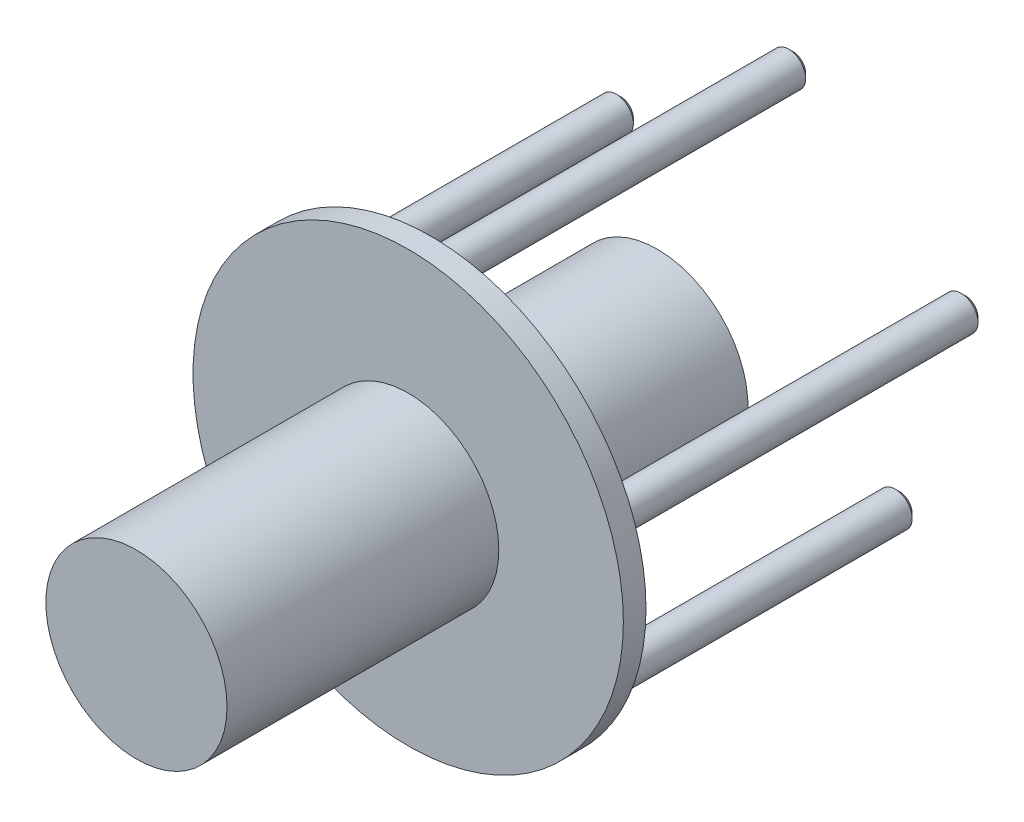
from build123d import *

# Parameters (mm, degrees)
SKETCH2_R             = 25.4
BOSS_EXTRUDE1_DEPTH   = 57.15
SKETCH2_R_2           = 4.7625
BOSS_EXTRUDE1_2_DEPTH = 57.15
BOSS_EXTRUDE1_3_DEPTH = 57.15
BOSS_EXTRUDE1_4_DEPTH = 57.15
BOSS_EXTRUDE1_5_DEPTH = 57.15
BOSS_EXTRUDE1_6_DEPTH = 57.15
SKETCH3_R             = 60.325
BOSS_EXTRUDE2_DEPTH   = 6.35
SKETCH4_R             = 25.4
BOSS_EXTRUDE3_DEPTH   = 6.35
SKETCH5_R             = 4.7625
BOSS_EXTRUDE4_DEPTH   = 44.45
CHAMFER1_SIZE         = 1.27
SKETCH7_R             = 25.4
BOSS_EXTRUDE5_DEPTH   = 76.2


with BuildPart() as part:
    # Sketch2 → Boss-Extrude1 (new body)
    with BuildSketch(Plane.XY):
        with Locations((-60.561942489, 11.211112057)):
            Circle(SKETCH2_R)
    extrude(amount=BOSS_EXTRUDE1_DEPTH)



with BuildPart() as body_2:
    # Sketch2 → Boss-Extrude1 2 (new body)
    with BuildSketch(Plane.XY):
        with Locations((-12.248271462, 26.909175371)):
            Circle(SKETCH2_R_2)
    extrude(amount=BOSS_EXTRUDE1_2_DEPTH)


with BuildPart() as body_3:
    # Sketch2 → Boss-Extrude1 3 (new body)
    with BuildSketch(Plane.XY):
        with Locations((-60.561942489, 62.011112057)):
            Circle(SKETCH2_R_2)
    extrude(amount=BOSS_EXTRUDE1_3_DEPTH)


with BuildPart() as body_4:
    # Sketch2 → Boss-Extrude1 4 (new body)
    with BuildSketch(Plane.XY):
        with Locations((-108.875613517, 26.909175371)):
            Circle(SKETCH2_R_2)
    extrude(amount=BOSS_EXTRUDE1_4_DEPTH)


with BuildPart() as body_5:
    # Sketch2 → Boss-Extrude1 5 (new body)
    with BuildSketch(Plane.XY):
        with Locations((-90.421433306, -29.886951258)):
            Circle(SKETCH2_R_2)
    extrude(amount=BOSS_EXTRUDE1_5_DEPTH)


with BuildPart() as body_6:
    # Sketch2 → Boss-Extrude1 6 (new body)
    with BuildSketch(Plane.XY):
        with Locations((-30.702451673, -29.886951258)):
            Circle(SKETCH2_R_2)
    extrude(amount=BOSS_EXTRUDE1_6_DEPTH)


with BuildPart() as part_1:
    add(part.part)

    add(body_2.part)  # Boss-Extrude2 merges body 2

    add(body_3.part)  # Boss-Extrude2 merges body 3

    add(body_4.part)  # Boss-Extrude2 merges body 4

    add(body_5.part)  # Boss-Extrude2 merges body 5

    add(body_6.part)  # Boss-Extrude2 merges body 6
    # Sketch3 → Boss-Extrude2 (add)
    with BuildSketch(Plane.XY.offset(57.15)):
        with Locations((-60.561942489, 11.211112057)):
            Circle(SKETCH3_R)
    extrude(amount=BOSS_EXTRUDE2_DEPTH)

    # Sketch4 → Boss-Extrude3 (add)
    with BuildSketch(Plane(origin=(0, 0, 0), x_dir=(-1, 0, 0), z_dir=(0, 0, -1))):
        with Locations((60.561942489, 11.211112057)):
            Circle(SKETCH4_R)
    extrude(amount=BOSS_EXTRUDE3_DEPTH)

    # Sketch5 → Boss-Extrude4 (add)
    with BuildSketch(Plane(origin=(0, 0, 0), x_dir=(-1, 0, 0), z_dir=(0, 0, -1))):
        with Locations((12.248271462, 26.909175371)):
            Circle(SKETCH5_R)
        with Locations((30.702451673, -29.886951258)):
            Circle(SKETCH5_R)
        with Locations((90.421433306, -29.886951258)):
            Circle(SKETCH5_R)
        with Locations((108.875613517, 26.909175371)):
            Circle(SKETCH5_R)
        with Locations((60.561942489, 62.011112057)):
            Circle(SKETCH5_R)
    extrude(amount=BOSS_EXTRUDE4_DEPTH)

    # Chamfer1
    chamfer1_edges = [part_1.edges().sort_by_distance(p)[0] for p in [
        (-7.485771462, 26.909175371, -44.45),
        (-25.939951673, -29.886951258, -44.45),
        (-85.658933306, -29.886951258, -44.45),
        (-104.113113517, 26.909175371, -44.45),
        (-55.799442489, 62.011112057, -44.45),
    ]]
    chamfer(chamfer1_edges, length=CHAMFER1_SIZE)

    # Sketch7 → Boss-Extrude5 (add)
    with BuildSketch(Plane.XY.offset(63.5)):
        with Locations((-60.561942489, 11.211112057)):
            Circle(SKETCH7_R)
    extrude(amount=BOSS_EXTRUDE5_DEPTH)


solid = part_1.part
